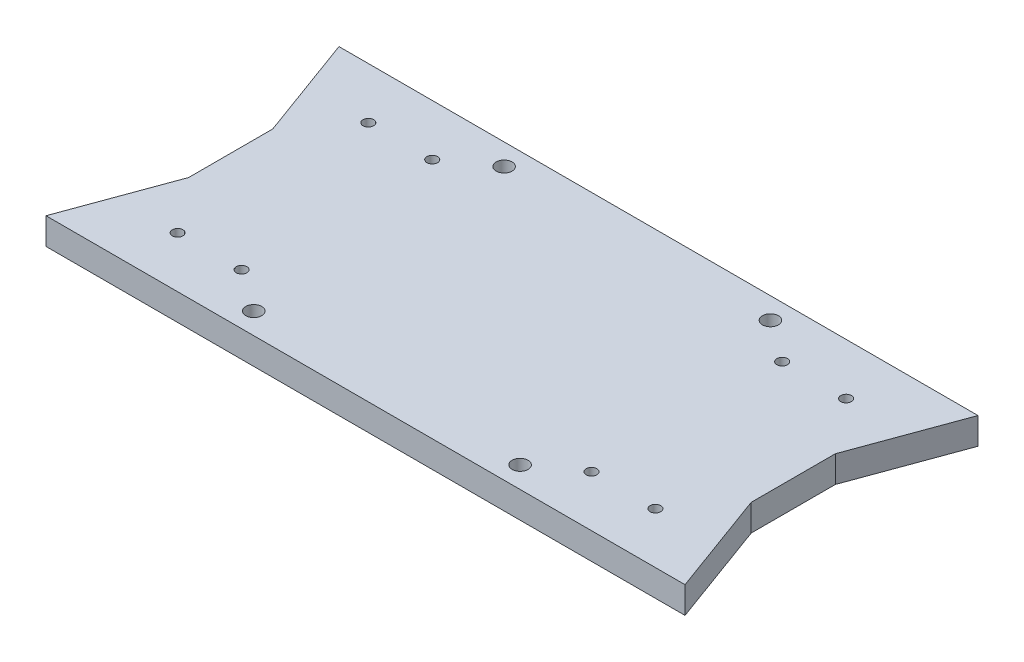
from build123d import *

# Parameters (mm, degrees)
SKETCH1_W           = 67.061286962
SKETCH1_H           = 69.85
SKETCH1_R           = 1.27
BOSS_EXTRUDE1_DEPTH = 6.35
SKETCH2_W           = 20.976278342
SKETCH2_H           = 20.060000012
BOSS_EXTRUDE2_DEPTH = 12.7
BOSS_EXTRUDE3_DEPTH = 6.35
SKETCH4_W           = 170.998259203
SKETCH4_H           = 17.997071231
CUT_EXTRUDE1_DEPTH  = 70.85
SKETCH8_R           = 1.905
CUT_EXTRUDE3_DEPTH  = 13.716


with BuildPart() as part:
    # Sketch1 → Boss-Extrude1 (new body)
    with BuildSketch(Plane(origin=(0, 0, 0), x_dir=(1, 0, 0), z_dir=(0, 1, 0))):
        with Locations((-4.803022, 67.707661351)):
            Rectangle(SKETCH1_W, SKETCH1_H)
        with Locations((3.381343157, 90.407661351)):
            Circle(SKETCH1_R, mode=Mode.SUBTRACT)
        with Locations((18.621343157, 90.407661351)):
            Circle(SKETCH1_R, mode=Mode.SUBTRACT)
        with Locations((3.381343157, 44.947661351)):
            Circle(SKETCH1_R, mode=Mode.SUBTRACT)
        with Locations((18.621343157, 44.947661351)):
            Circle(SKETCH1_R, mode=Mode.SUBTRACT)
    boss_extrude1 = extrude(amount=BOSS_EXTRUDE1_DEPTH)

    # Sketch2 → Boss-Extrude2 (add)
    with BuildSketch(Plane(origin=(0, 6.35, 0), x_dir=(1, 0, 0), z_dir=(0, 1, 0))):
        with Locations((18.23948231, 67.707661351)):
            Rectangle(SKETCH2_W, SKETCH2_H)
    boss_extrude2 = extrude(amount=BOSS_EXTRUDE2_DEPTH)

    # Sketch3 → Boss-Extrude3 (add)
    with BuildSketch(Plane(origin=(0, 6.35, 0), x_dir=(1, 0, 0), z_dir=(0, 1, 0))):
        Polygon((37.841343157, 102.632661351), (28.727621481, 77.737661357), (28.727621481, 102.632661351), align=None)
        Polygon((28.727621481, 57.677661345), (37.841343157, 32.782661351), (28.727621481, 32.782661351), align=None)
    boss_extrude3 = extrude(amount=-BOSS_EXTRUDE3_DEPTH)

    # Mirror2: Boss-Extrude1, Boss-Extrude2, Boss-Extrude3 across plane
    add(boss_extrude1.mirror(Plane(origin=(-38.333665481, 6.35, -32.782661351), x_dir=(0, 0, 1), z_dir=(1, 0, 0))))
    add(boss_extrude2.mirror(Plane(origin=(-38.333665481, 6.35, -32.782661351), x_dir=(0, 0, 1), z_dir=(1, 0, 0))))
    add(boss_extrude3.mirror(Plane(origin=(-38.333665481, 6.35, -32.782661351), x_dir=(0, 0, 1), z_dir=(1, 0, 0))))

    # Sketch4 → Cut-Extrude1 (cut, through all)
    with BuildSketch(Plane.XY.offset(-32.782661351)):
        with Locations((-47.657786445, 15.348535616)):
            Rectangle(SKETCH4_W, SKETCH4_H)
    extrude(amount=-CUT_EXTRUDE1_DEPTH, mode=Mode.SUBTRACT)

    # Sketch8 → Cut-Extrude3 (cut)
    with BuildSketch(Plane(origin=(0, 6.35, 0), x_dir=(1, 0, 0), z_dir=(0, 1, 0))):
        with Locations((-6.558674119, 97.552661351)):
            Circle(SKETCH8_R)
        with Locations((-6.558674119, 37.862661351)):
            Circle(SKETCH8_R)
        with Locations((-171.91881552, 187.895953706)):
            Circle(SKETCH8_R)
        with Locations((-70.058674119, 97.552661351)):
            Circle(SKETCH8_R)
        with Locations((-70.058674119, 37.862661351)):
            Circle(SKETCH8_R)
    extrude(amount=-CUT_EXTRUDE3_DEPTH, mode=Mode.SUBTRACT)


solid = part.part
